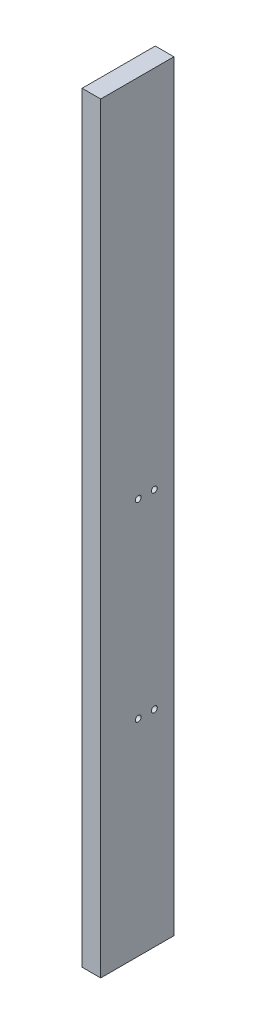
from build123d import *

# Parameters (mm, degrees)
SKETCH1_W           = 50
SKETCH1_H           = 520
BOSS_EXTRUDE1_DEPTH = 12.7
SKETCH5_R           = 2
CUT_EXTRUDE1_DEPTH  = 13.7


with BuildPart() as part:
    # Sketch1 → Boss-Extrude1 (new body)
    with BuildSketch(Plane(origin=(0, 0, 0), x_dir=(0, 0, -1), z_dir=(1, 0, 0))):
        Rectangle(SKETCH1_W, SKETCH1_H)
    extrude(amount=BOSS_EXTRUDE1_DEPTH)

    # Sketch5 → Cut-Extrude1 (cut, through all)
    with BuildSketch(Plane.ZY):
        with Locations((-11.65, 10.609140035)):
            Circle(SKETCH5_R)
        with Locations((-0.65, 10.609140035)):
            Circle(SKETCH5_R)
        with Locations((-11.65, -119.390859965)):
            Circle(SKETCH5_R)
        with Locations((-0.65, -119.390859965)):
            Circle(SKETCH5_R)
    extrude(amount=-CUT_EXTRUDE1_DEPTH, mode=Mode.SUBTRACT)


solid = part.part
